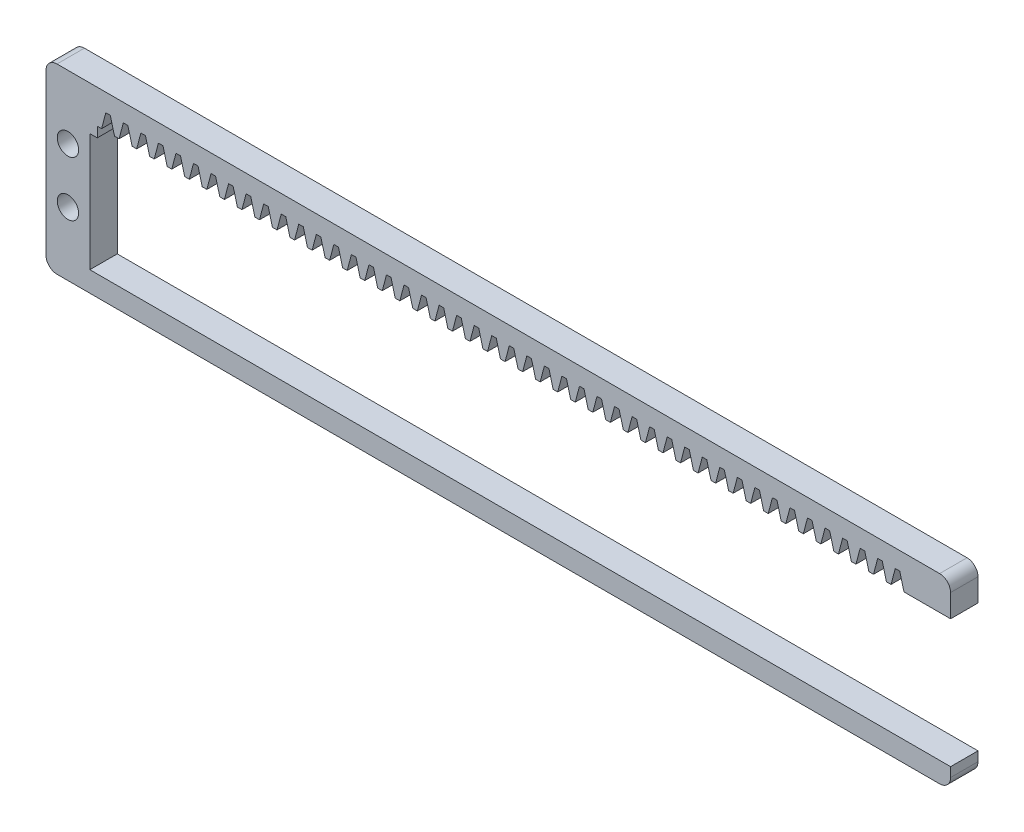
from build123d import *

# Parameters (mm, degrees)
BOSS_EXTRUDE1_DEPTH = 5
SKETCH2_W           = 149
SKETCH2_H           = 21.5
CUT_EXTRUDE1_DEPTH  = 6
SKETCH3_W           = 145.97
SKETCH3_H           = 1.85
CUT_EXTRUDE2_DEPTH  = 6
CUT_EXTRUDE4_DEPTH  = 6
LPATTERN1_COUNT     = 46
LPATTERN1_PITCH     = 3.2
SKETCH5_R           = 1.95
CUT_EXTRUDE5_DEPTH  = 10
SKETCH8_W           = 12.491366173
SKETCH8_H           = 5
CUT_EXTRUDE6_DEPTH  = 23.35


with BuildPart() as part:
    # Sketch1 → Boss-Extrude1 (new body)
    with BuildSketch(Plane.XY):
        with BuildLine():
            Line((2, 0), (163, 0))
            ThreePointArc((163, 0), (164.414213562, -0.585786438), (165, -2))
            Line((165, -2), (165, -31.22))
            ThreePointArc((165, -31.22), (164.414213562, -32.634213562), (163, -33.22))
            Line((163, -33.22), (2, -33.22))
            ThreePointArc((2, -33.22), (0.585786438, -32.634213562), (0, -31.22))
            Line((0, -31.22), (0, -2))
            ThreePointArc((0, -2), (0.585786438, -0.585786438), (2, 0))
        make_face()
    extrude(amount=BOSS_EXTRUDE1_DEPTH)

    # Sketch2 → Cut-Extrude1 (cut, through all)
    with BuildSketch(Plane.XY.offset(5)):
        with Locations((82.5, -18.75)):
            Rectangle(SKETCH2_W, SKETCH2_H)
    extrude(amount=-CUT_EXTRUDE1_DEPTH, mode=Mode.SUBTRACT)

    # Sketch3 → Cut-Extrude2 (cut, through all)
    with BuildSketch(Plane.XY.offset(5)):
        with Locations((82.335, -7.075)):
            Rectangle(SKETCH3_W, SKETCH3_H)
    extrude(amount=-CUT_EXTRUDE2_DEPTH, mode=Mode.SUBTRACT)

    # Sketch4 → Cut-Extrude4 (cut, through all)
    with BuildSketch(Plane.XY.offset(5)):
        Polygon((155.735, -3.249176841), (156.5, -6.15), (154.14, -6.15), (154.905, -3.249176841), align=None)
    cut_extrude4 = extrude(amount=-CUT_EXTRUDE4_DEPTH, mode=Mode.SUBTRACT)

    # LPattern1: Cut-Extrude4 ×46
    with Locations(*[(-i * LPATTERN1_PITCH, 0, 0) for i in range(1, LPATTERN1_COUNT)]):
        add(cut_extrude4, mode=Mode.SUBTRACT)

    # Sketch5 → Cut-Extrude5 (cut)
    with BuildSketch(Plane.XY.offset(5)):
        with Locations((4, -11.61)):
            Circle(SKETCH5_R)
        with Locations((4, -21.61)):
            Circle(SKETCH5_R)
        with Locations((161, -11.61)):
            Circle(SKETCH5_R)
        with Locations((161, -21.61)):
            Circle(SKETCH5_R)
    extrude(amount=-CUT_EXTRUDE5_DEPTH, mode=Mode.SUBTRACT)

    # Sketch8 → Cut-Extrude6 (cut)
    with BuildSketch(Plane(origin=(0, -29.5, 0), x_dir=(1, 0, 0), z_dir=(0, 1, 0))):
        with Locations((158.754316914, -2.5)):
            Rectangle(SKETCH8_W, SKETCH8_H)
    extrude(amount=CUT_EXTRUDE6_DEPTH, mode=Mode.SUBTRACT)


solid = part.part
